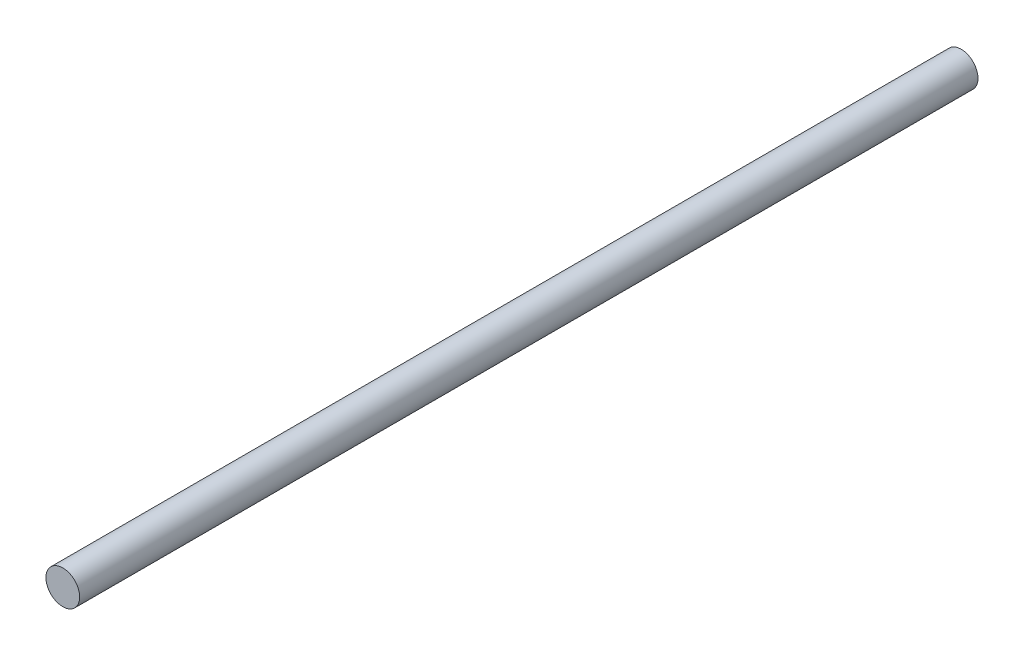
from build123d import *

# Parameters (mm, degrees)
SKETCH_1_R      = 15
EXTRUDE_1_DEPTH = 800


with BuildPart() as part:
    # 草圖1 → 填料-伸長1 (new body)
    with BuildSketch(Plane.XY):
        Circle(SKETCH_1_R)
    extrude(amount=EXTRUDE_1_DEPTH)


solid = part.part
